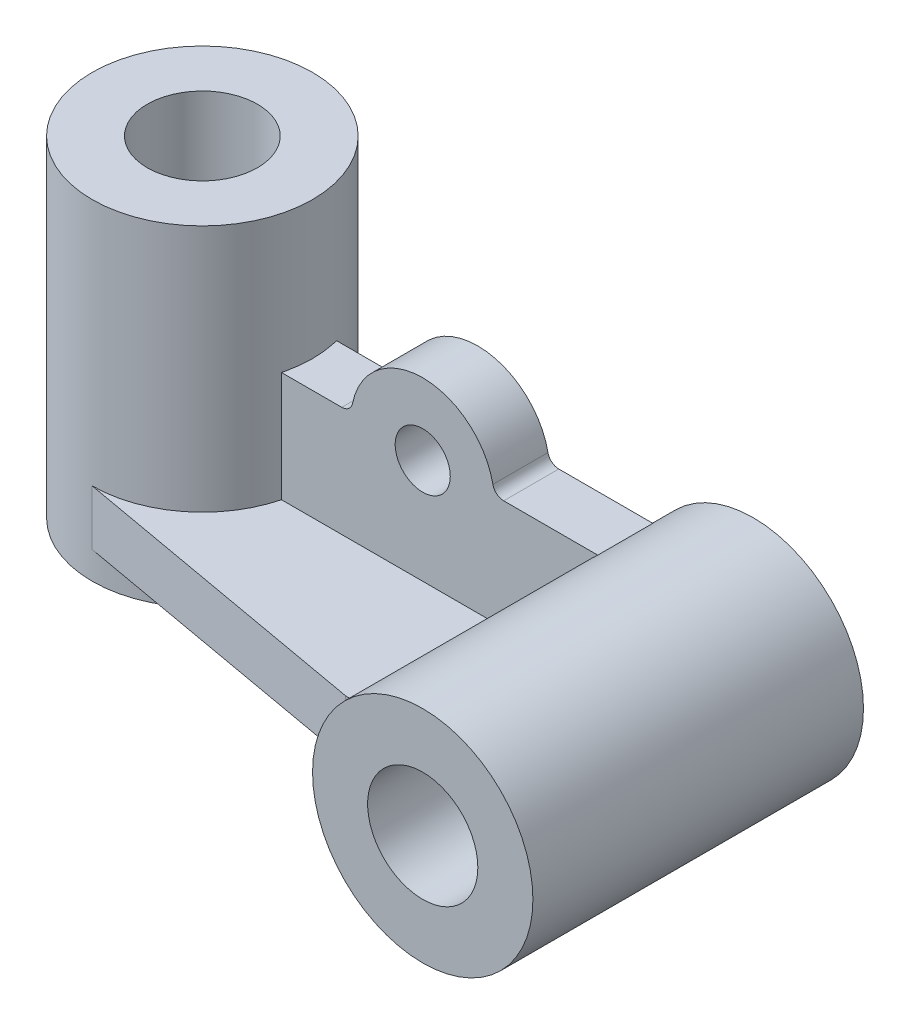
from build123d import *

# Parameters (mm, degrees)
SKETCH1_W         = 10
SKETCH1_H         = 60
SKETCH3_R         = 20
SKETCH3_R_2       = 10
CYL_BLUE_DEPTH    = 60
SKETCH4_R         = 5
BASE_YELLOW_DEPTH = 10
BASE_RED_DEPTH    = 10


with BuildPart() as part:
    # Sketch1 → cyl- purple (revolve)
    with BuildSketch(Plane.XY):
        with Locations((15, 0)):
            Rectangle(SKETCH1_W, SKETCH1_H)
    revolve(axis=Axis((0, 30, 0), (0, -1, 0)))


with BuildPart() as body_2:
    # Sketch3 → cyl- blue (new body)
    with BuildSketch(Plane.XY.offset(50)):
        with Locations((90, -10)):
            Circle(SKETCH3_R)
        with Locations((90, -10)):
            Circle(SKETCH3_R_2, mode=Mode.SUBTRACT)
    extrude(amount=-CYL_BLUE_DEPTH)


with BuildPart() as body_3:
    # Sketch4 → base- yellow (new body)
    with BuildSketch(Plane.XY.offset(-5)):
        with BuildLine():
            Line((10, -15), (70.635083269, -15))
            ThreePointArc((70.635083269, -15), (70.879673523, -4.133730706), (76.771243445, 5))
            Line((76.771243445, 5), (59.696938457, 5))
            ThreePointArc((59.696938457, 5), (58.432027393, 5.450806662), (57.737346662, 6.6))
            ThreePointArc((57.737346662, 6.6), (45, 17), (32.262653338, 6.6))
            ThreePointArc((32.262653338, 6.6), (31.567972607, 5.450806662), (30.303061543, 5))
            Line((30.303061543, 5), (10, 5))
            Line((10, 5), (10, -15))
        make_face()
        with Locations((45, 4)):
            Circle(SKETCH4_R, mode=Mode.SUBTRACT)
    extrude(amount=BASE_YELLOW_DEPTH)


with BuildPart() as body_4:
    # Sketch6 → base-red (new body)
    with BuildSketch(Plane(origin=(0, -25, 0), x_dir=(1, 0, 0), z_dir=(0, 1, 0))):
        with BuildLine():
            Line((0, -20), (56, -30))
            Line((56, -30), (77.309100809, -30))
            Line((77.309100809, -30), (77.309100809, -5))
            Line((77.309100809, -5), (19.364916731, -5))
            ThreePointArc((19.364916731, -5), (12.247448714, -15.811388301), (0, -20))
        make_face()
    extrude(amount=BASE_RED_DEPTH)


solid = Compound([part.part, body_2.part, body_3.part, body_4.part])
